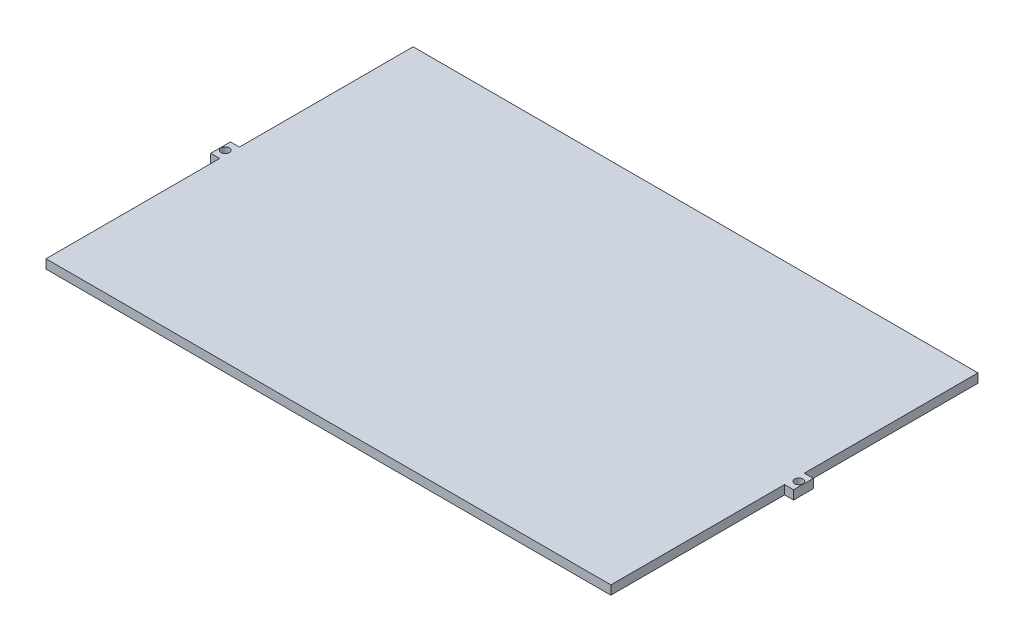
from build123d import *

# Parameters (mm, degrees)
SKETCH2_W           = 200
SKETCH2_H           = 130
BOSS_EXTRUDE1_DEPTH = 3.18
SKETCH5_W           = 7
SKETCH5_H           = 3.18
BOSS_EXTRUDE2_DEPTH = 3.18
SKETCH11_R          = 1.47
CUT_EXTRUDE5_DEPTH  = 3.18


with BuildPart() as part:
    # Sketch2 → Boss-Extrude1 (new body)
    with BuildSketch(Plane(origin=(0, 0, 0), x_dir=(1, 0, 0), z_dir=(0, 1, 0))):
        Rectangle(SKETCH2_W, SKETCH2_H)
    extrude(amount=BOSS_EXTRUDE1_DEPTH)

    # Sketch5 → Boss-Extrude2 (add)
    with BuildSketch(Plane.ZY.offset(100)):
        with Locations((0, 1.59)):
            Rectangle(SKETCH5_W, SKETCH5_H)
    boss_extrude2 = extrude(amount=BOSS_EXTRUDE2_DEPTH)

    # Sketch11 → Cut-Extrude5 (cut)
    with BuildSketch(Plane(origin=(0, 3.18, 0), x_dir=(1, 0, 0), z_dir=(0, 1, 0))):
        with Locations((-101.55, 0)):
            Circle(SKETCH11_R)
    cut_extrude5 = extrude(amount=-CUT_EXTRUDE5_DEPTH, mode=Mode.SUBTRACT)

    # Mirror1: Boss-Extrude2, Cut-Extrude5 across plane
    add(boss_extrude2.mirror(Plane(origin=(0, 0, 0), x_dir=(0, 0, 1), z_dir=(1, 0, 0))))
    add(cut_extrude5.mirror(Plane(origin=(0, 0, 0), x_dir=(0, 0, 1), z_dir=(1, 0, 0))), mode=Mode.SUBTRACT)


solid = part.part
